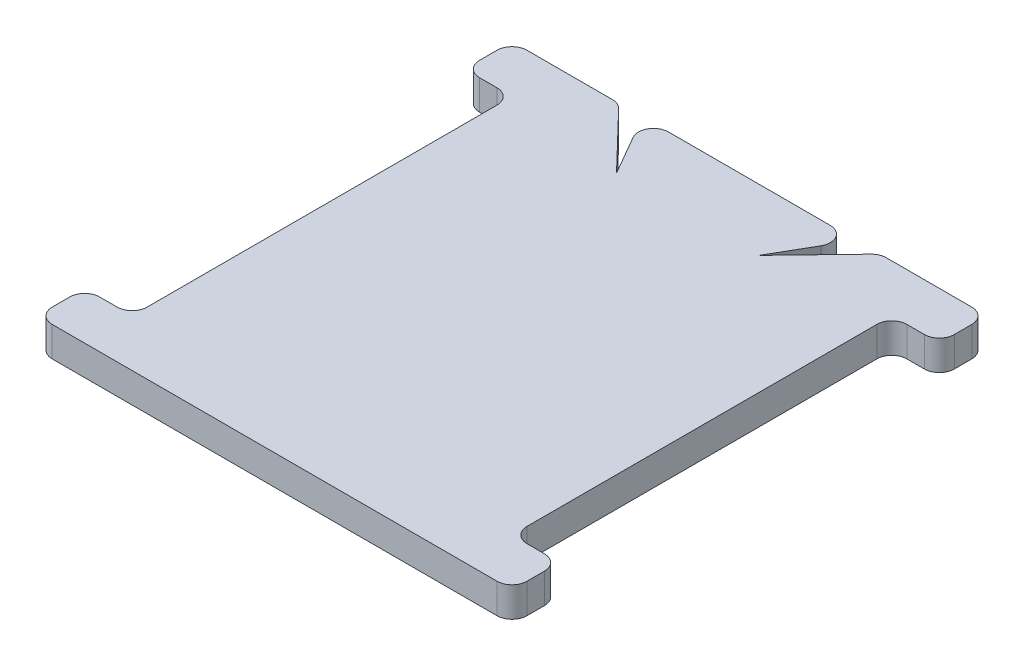
from build123d import *

# Parameters (mm, degrees)
BOSS_EXTRUDE1_DEPTH  = 1
FILLET1_R            = 1
CUT_EXTRUDE1_START   = -3
CUT_EXTRUDE1_DEPTH   = 4
FILLET2_R            = 1
FILLET2_OF_MIRROR1_R = 1


with BuildPart() as part:
    # Sketch1 → Boss-Extrude1 (new body, symmetric)
    with BuildSketch(Plane(origin=(0, 0, 0), x_dir=(1, 0, 0), z_dir=(0, 1, 0))):
        Polygon((12.7, 12.7), (15.875, 12.7), (15.875, 15.875), (-15.875, 15.875), (-15.875, 12.7), (-12.7, 12.7), (-12.7, -12.7), (-15.875, -12.7), (-15.875, -15.875), (15.875, -15.875), (15.875, -12.7), (12.7, -12.7), align=None)
    extrude(amount=BOSS_EXTRUDE1_DEPTH, both=True)

    # Fillet1
    fillet1_edges = [part.edges().sort_by_distance(p)[0] for p in [
        (12.7, 0, 12.7),
        (15.875, 0, 12.7),
        (15.875, 0, 15.875),
        (-15.875, 0, 15.875),
        (-15.875, 0, 12.7),
        (-12.7, 0, 12.7),
        (-12.7, 0, -12.7),
        (-15.875, 0, -12.7),
        (-15.875, 0, -15.875),
        (15.875, 0, -15.875),
        (15.875, 0, -12.7),
        (12.7, 0, -12.7),
    ]]
    fillet(fillet1_edges, radius=FILLET1_R)

    # Sketch2 → Cut-Extrude1 (cut)
    with BuildSketch(Plane(origin=(0, 1, 0), x_dir=(1, 0, 0), z_dir=(0, 1, 0)).offset(CUT_EXTRUDE1_START)):
        Polygon((-8.73125, 15.875), (-4.7625, 11.750554014), (-7.14375, 15.875), align=None)
    cut_extrude1 = extrude(amount=CUT_EXTRUDE1_DEPTH, mode=Mode.SUBTRACT)

    # Fillet2
    fillet2_edges = [part.edges().sort_by_distance(p)[0] for p in [
        (-7.14375, 0, -15.875),
        (-8.73125, 0, -15.875),
    ]]
    fillet(fillet2_edges, radius=FILLET2_R)

    # Mirror1: Cut-Extrude1 across plane
    add(cut_extrude1.mirror(Plane(origin=(0, 0, 0), x_dir=(0, 0, 1), z_dir=(1, 0, 0))), mode=Mode.SUBTRACT)

    # Fillet2 of Mirror1
    fillet2_of_mirror1_edges = [part.edges().sort_by_distance(p)[0] for p in [
        (7.14375, 0, -15.875),
        (8.73125, 0, -15.875),
    ]]
    fillet(fillet2_of_mirror1_edges, radius=FILLET2_OF_MIRROR1_R)


solid = part.part
